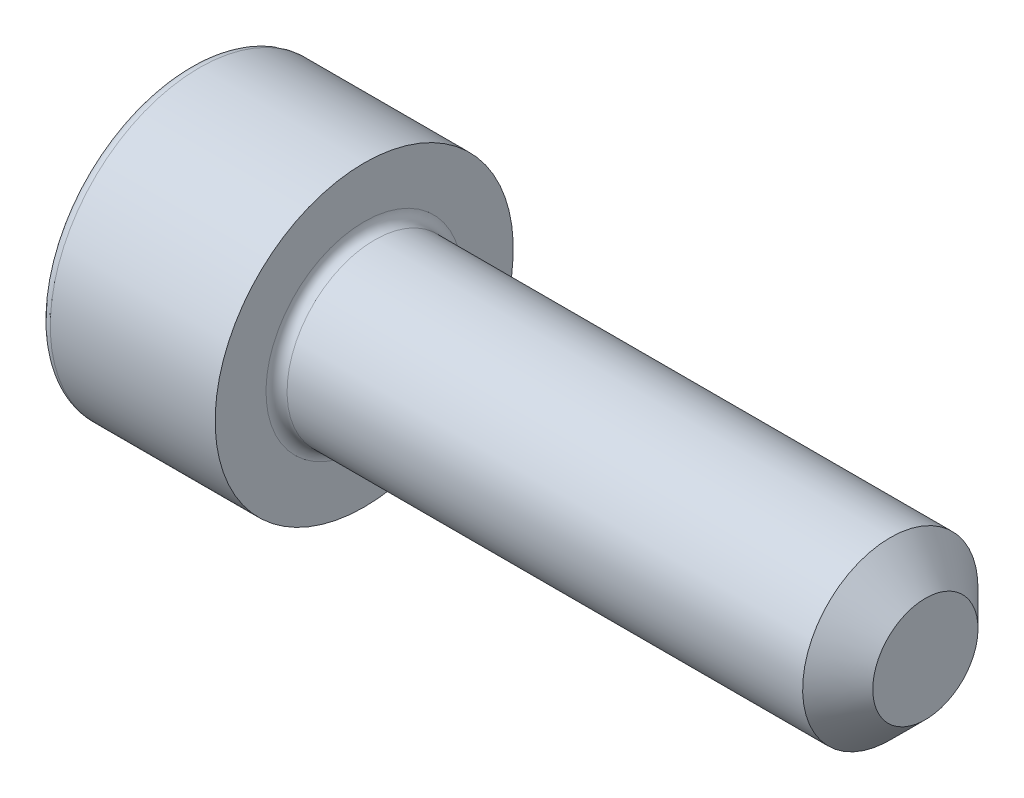
from build123d import *

# Parameters (mm, degrees)
CUT_EXTRUDE_1_DEPTH = 2.5
FILLET_1_R          = 0.3
CHAMFER_1_SIZE      = 1


with BuildPart() as part:
    # Эскиз1 → Повернуть1 (revolve)
    with BuildSketch(Plane.XY):
        Polygon((0, 0), (0, 4.25), (5, 4.25), (5, 2.5), (21, 2.5), (21, 0), align=None)
    revolve(axis=Axis((21, 0, 0), (-1, 0, 0)))

    # Эскиз2 → Вырез-Вытянуть1 (cut)
    with BuildSketch(Plane.ZY):
        Polygon((-1.154700538, 2), (-2.309401077, 0), (-1.154700538, -2), (1.154700538, -2), (2.309401077, 0), (1.154700538, 2), align=None)
    extrude(amount=-CUT_EXTRUDE_1_DEPTH, mode=Mode.SUBTRACT)

    # Скругление1
    fillet_1_edges = [part.edges().sort_by_distance(p)[0] for p in [
        (5, -2.5, 0),
        (0, -4.25, 0),
    ]]
    fillet(fillet_1_edges, radius=FILLET_1_R)

    # Фаска1
    chamfer_1_edges = [part.edges().sort_by_distance(p)[0] for p in [
        (21, -2.5, 0),
    ]]
    chamfer(chamfer_1_edges, length=CHAMFER_1_SIZE)


solid = part.part
